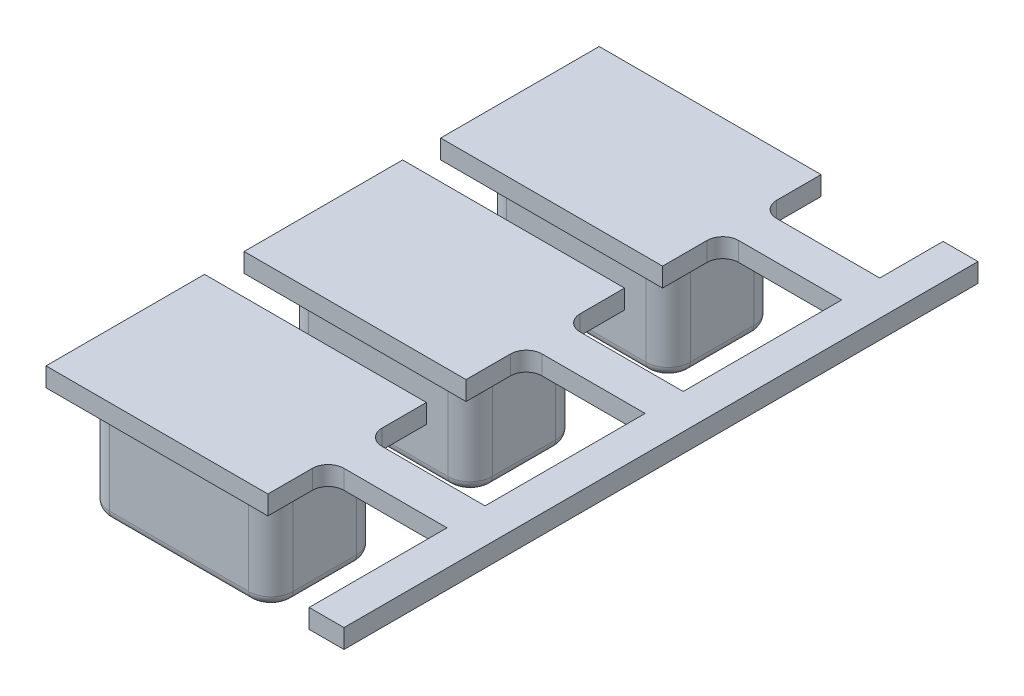
from build123d import *

# Parameters (mm, degrees)
EXTRUDE_1_DEPTH      = 4
EXTRUDE_1_2_DEPTH    = 4
EXTRUDE_1_3_DEPTH    = 4
SKETCH_2_W           = 7
SKETCH_2_H           = 5
EXTRUDE_2_DEPTH      = 0.6
SKETCH_3_W           = 4.85
SKETCH_3_H           = 1.2
EXTRUDE_3_DEPTH      = 0.6
SKETCH_4_W           = 1
SKETCH_4_H           = 13.65
EXTRUDE_4_DEPTH      = 0.6
FILLET_1_R           = 0.5
FILLET_2_R           = 0.3
SKETCH_5_W           = 1.1
SKETCH_5_H           = 0.6
EXTRUDE_5_DEPTH      = 2
EXTRUDE_5_DEPTH_BACK = 18


with BuildPart() as part:
    # 草图1 → 凸台-拉伸1 (new body)
    with BuildSketch(Plane(origin=(0, 0, 0), x_dir=(1, 0, 0), z_dir=(0, 1, 0))):
        with BuildLine():
            Line((-2.2, 1.245389122), (2.2, 1.245389122))
            ThreePointArc((2.2, 1.245389122), (2.694974747, 1.040363869), (2.9, 0.545389122))
            Line((2.9, 0.545389122), (2.9, -1.454610878))
            ThreePointArc((2.9, -1.454610878), (2.694974747, -1.949585625), (2.2, -2.154610878))
            Line((2.2, -2.154610878), (-2.2, -2.154610878))
            ThreePointArc((-2.2, -2.154610878), (-2.694974747, -1.949585625), (-2.9, -1.454610878))
            Line((-2.9, -1.454610878), (-2.9, 0.545389122))
            ThreePointArc((-2.9, 0.545389122), (-2.694974747, 1.040363869), (-2.2, 1.245389122))
        make_face()
    extrude(amount=EXTRUDE_1_DEPTH)



with BuildPart() as body_2:
    # 草图1 → Extrude 1 2 (new body)
    with BuildSketch(Plane(origin=(0, 0, 0), x_dir=(1, 0, 0), z_dir=(0, 1, 0))):
        with BuildLine():
            Line((-2.2, 7.528722779), (2.2, 7.528722779))
            ThreePointArc((2.2, 7.528722779), (2.694974747, 7.323697526), (2.9, 6.828722779))
            Line((2.9, 6.828722779), (2.9, 4.828722779))
            ThreePointArc((2.9, 4.828722779), (2.694974747, 4.333748032), (2.2, 4.128722779))
            Line((2.2, 4.128722779), (-2.2, 4.128722779))
            ThreePointArc((-2.2, 4.128722779), (-2.694974747, 4.333748032), (-2.9, 4.828722779))
            Line((-2.9, 4.828722779), (-2.9, 6.828722779))
            ThreePointArc((-2.9, 6.828722779), (-2.694974747, 7.323697526), (-2.2, 7.528722779))
        make_face()
    extrude(amount=EXTRUDE_1_2_DEPTH)


with BuildPart() as body_3:
    # 草图1 → Extrude 1 3 (new body)
    with BuildSketch(Plane(origin=(0, 0, 0), x_dir=(1, 0, 0), z_dir=(0, 1, 0))):
        with BuildLine():
            Line((-2.2, 13.775919566), (2.2, 13.775919566))
            ThreePointArc((2.2, 13.775919566), (2.694974747, 13.570894313), (2.9, 13.075919566))
            Line((2.9, 13.075919566), (2.9, 11.075919566))
            ThreePointArc((2.9, 11.075919566), (2.694974747, 10.580944819), (2.2, 10.375919566))
            Line((2.2, 10.375919566), (-2.2, 10.375919566))
            ThreePointArc((-2.2, 10.375919566), (-2.694974747, 10.580944819), (-2.9, 11.075919566))
            Line((-2.9, 11.075919566), (-2.9, 13.075919566))
            ThreePointArc((-2.9, 13.075919566), (-2.694974747, 13.570894313), (-2.2, 13.775919566))
        make_face()
    extrude(amount=EXTRUDE_1_3_DEPTH)


with BuildPart() as part_1:
    add(part.part)

    add(body_2.part)  # 凸台-拉伸2 merges body 2

    add(body_3.part)  # 凸台-拉伸2 merges body 3
    # 草图2 → 凸台-拉伸2 (add)
    with BuildSketch(Plane(origin=(0, 4, 0), x_dir=(1, 0, 0), z_dir=(0, 1, 0))):
        with Locations((0.036699987, 12.063062551)):
            Rectangle(SKETCH_2_W, SKETCH_2_H)
        with Locations((0.036699987, 5.863062551)):
            Rectangle(SKETCH_2_W, SKETCH_2_H)
        with Locations((0.036699987, -0.386937449)):
            Rectangle(SKETCH_2_W, SKETCH_2_H)
    extrude(amount=-EXTRUDE_2_DEPTH)

    # 草图3 → 凸台-拉伸3 (add)
    with BuildSketch(Plane(origin=(0, 4, 0), x_dir=(1, 0, 0), z_dir=(0, 1, 0))):
        with Locations((5.961699987, 12.063062551)):
            Rectangle(SKETCH_3_W, SKETCH_3_H)
        with Locations((5.961699987, 5.863062551)):
            Rectangle(SKETCH_3_W, SKETCH_3_H)
        with Locations((5.961699987, -0.386937449)):
            Rectangle(SKETCH_3_W, SKETCH_3_H)
    extrude(amount=-EXTRUDE_3_DEPTH)

    # 草图4 → 凸台-拉伸4 (add)
    with BuildSketch(Plane.XZ.offset(-3.4)):
        with Locations((7.886699987, -5.838062551)):
            Rectangle(SKETCH_4_W, SKETCH_4_H)
    extrude(amount=-EXTRUDE_4_DEPTH)

    # 圆角1
    fillet_1_edges = [part_1.edges().sort_by_distance(p)[0] for p in [
        (3.536699987, 3.7, -11.463062551),
        (3.536699987, 3.7, -12.663062551),
        (3.536699987, 3.7, 0.986937449),
        (3.536699987, 3.7, -0.213062551),
        (3.536699987, 3.7, -5.263062551),
        (3.536699987, 3.7, -6.463062551),
    ]]
    fillet(fillet_1_edges, radius=FILLET_1_R)

    # 圆角2
    fillet_2_edges = [part_1.edges().sort_by_distance(p)[0] for p in [
        (-2.9, 0, 0.454610878),
        (-2.694974747, 0, -1.040363869),
        (-2.694974747, 0, -13.570894313),
        (-2.9, 0, -12.075919566),
        (-2.694974747, 0, -10.580944819),
        (0, 0, -10.375919566),
        (2.694974747, 0, -10.580944819),
        (2.9, 0, -12.075919566),
        (2.694974747, 0, -13.570894313),
        (0, 0, -13.775919566),
        (0, 0, -1.245389122),
        (2.694974747, 0, -1.040363869),
        (2.9, 0, 0.454610878),
        (2.694974747, 0, 1.949585625),
        (-2.694974747, 0, -7.323697526),
        (-2.9, 0, -5.828722779),
        (-2.694974747, 0, -4.333748032),
        (0, 0, -4.128722779),
        (2.694974747, 0, -4.333748032),
        (2.9, 0, -5.828722779),
        (0, 0, 2.154610878),
        (2.694974747, 0, -7.323697526),
        (0, 0, -7.528722779),
        (-2.694974747, 0, 1.949585625),
    ]]
    fillet(fillet_2_edges, radius=FILLET_2_R)

    # 草图5 → 凸台-拉伸5 (add, two sides)
    with BuildSketch(Plane(origin=(0, 0, -12.663062551), x_dir=(-1, 0, 0), z_dir=(0, 0, -1))) as extrude_5_sk:
        with Locations((-7.836699987, 3.7)):
            Rectangle(SKETCH_5_W, SKETCH_5_H)
    extrude(amount=EXTRUDE_5_DEPTH)
    extrude(extrude_5_sk.sketch, amount=-EXTRUDE_5_DEPTH_BACK)


solid = part_1.part
